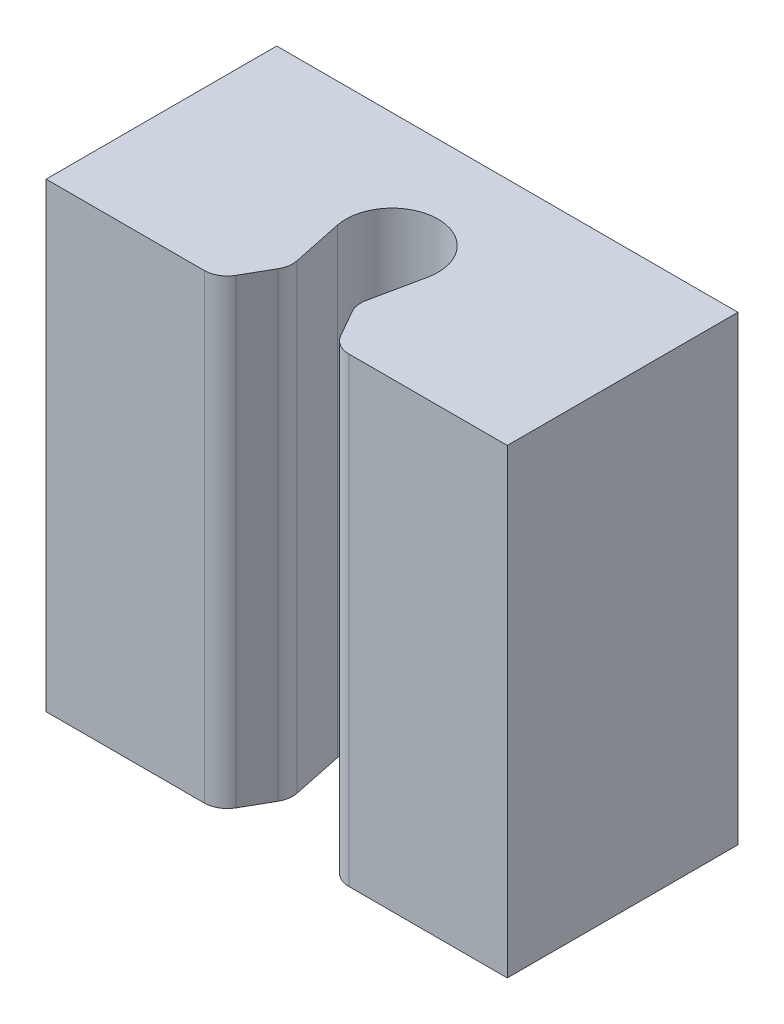
from build123d import *

# Parameters (mm, degrees)
SKIZZE1_W                       = 100
SKIZZE1_H                       = 100
AUFSATZ_LINEAR_AUSTRAGEN1_DEPTH = 50
SCHNITT_LINEAR_AUSTRAGEN1_DEPTH = 101
VERRUNDUNG1_R                   = 5


with BuildPart() as part:
    # Skizze1 → Aufsatz-Linear austragen1 (new body)
    with BuildSketch(Plane.XY):
        Rectangle(SKIZZE1_W, SKIZZE1_H)
    extrude(amount=AUFSATZ_LINEAR_AUSTRAGEN1_DEPTH)

    # Skizze2 → Schnitt-Linear austragen1 (cut, through all)
    with BuildSketch(Plane.XZ.offset(50)):
        with BuildLine():
            ThreePointArc((-9.789261077, 27.042147785), (0, 15), (9.789261077, 27.042147785))
            Line((9.789261077, 27.042147785), (7.086110247, 40))
            Line((7.086110247, 40), (12.79015, 50))
            Line((12.79015, 50), (-12.79015, 50))
            Line((-12.79015, 50), (-7.086110247, 40))
            Line((-7.086110247, 40), (-9.789261077, 27.042147785))
        make_face()
    extrude(amount=-SCHNITT_LINEAR_AUSTRAGEN1_DEPTH, mode=Mode.SUBTRACT)

    # Verrundung1
    verrundung1_edges = [part.edges().sort_by_distance(p)[0] for p in [
        (-12.79015, 0, 50),
        (12.79015, 0, 50),
        (7.086110247, 0, 40),
        (-7.086110247, 0, 40),
    ]]
    fillet(verrundung1_edges, radius=VERRUNDUNG1_R)


solid = part.part
